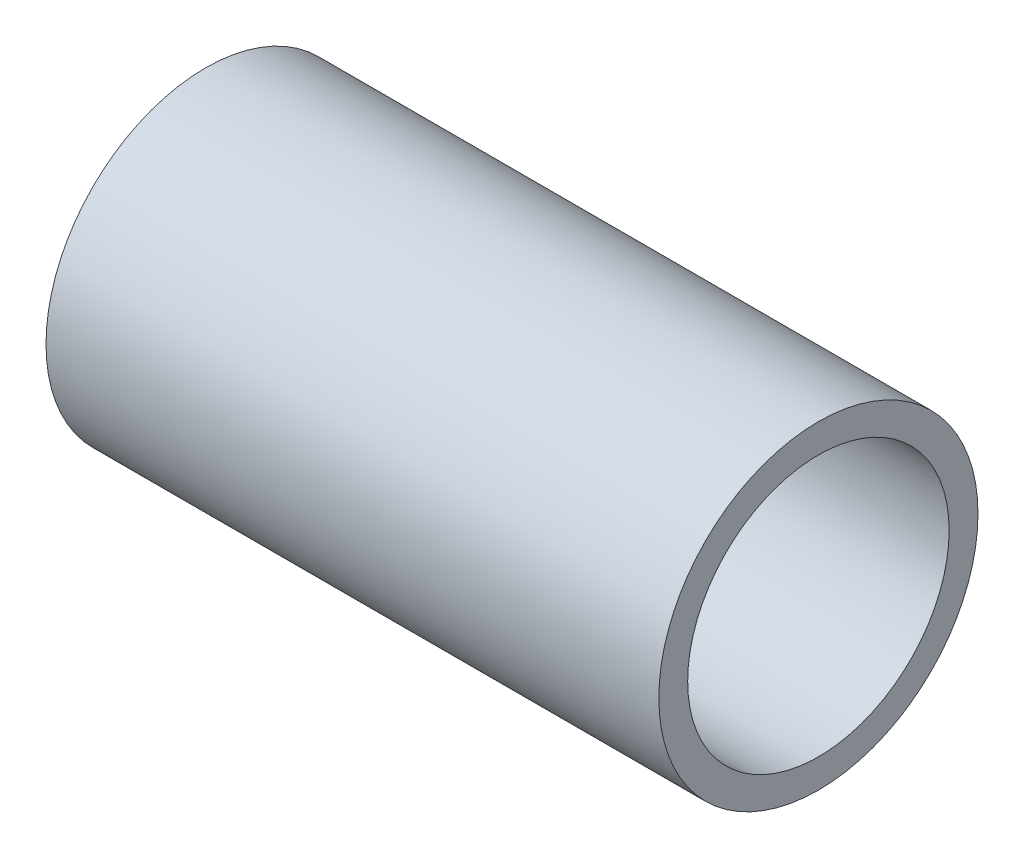
from build123d import *

# Parameters (mm, degrees)
SKETCH1_R           = 1.984375
SKETCH1_R_2         = 1.6256
BOSS_EXTRUDE1_DEPTH = 7.62


with BuildPart() as part:
    # Sketch1 → Boss-Extrude1 (new body)
    with BuildSketch(Plane(origin=(0, 0, 0), x_dir=(0, 0, -1), z_dir=(1, 0, 0))):
        Circle(SKETCH1_R)
        Circle(SKETCH1_R_2, mode=Mode.SUBTRACT)
    extrude(amount=BOSS_EXTRUDE1_DEPTH)


solid = part.part
